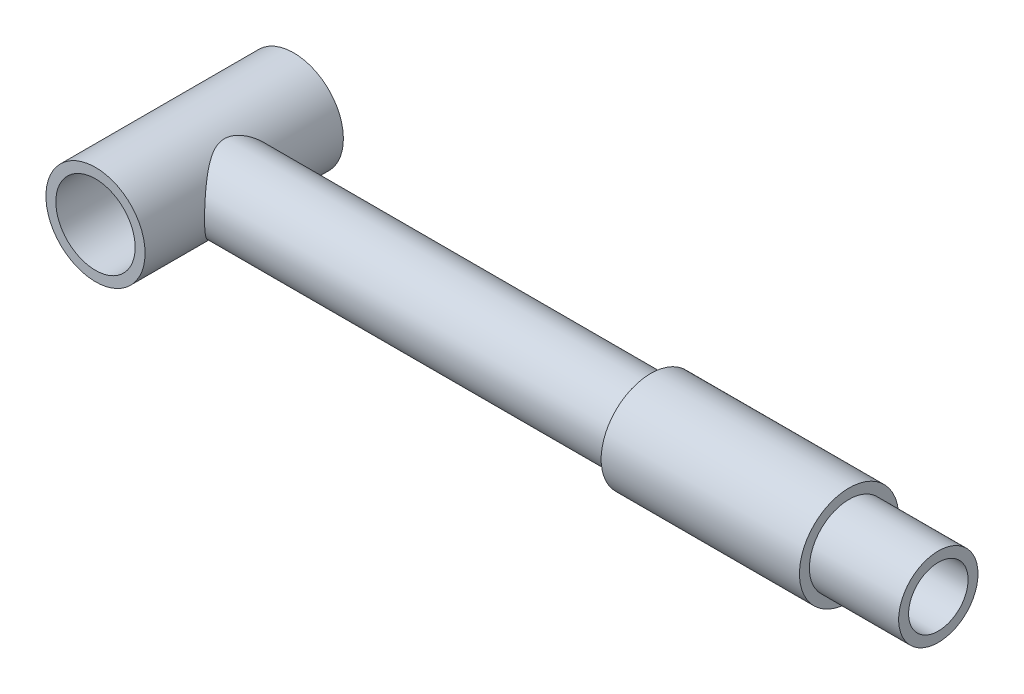
from build123d import *

# Parameters (mm, degrees)
IZIM1_R                                 = 2.5
IZIM1_R_2                               = 2
Y_KSEKLIK_EKSTR_ZYON1_DEPTH             = 5
IZIM2_R                                 = 2
IZIM2_R_2                               = 1.5
Y_KSEKLIK_EKSTR_ZYON2_DEPTH             = 35
Y_KSEKLIK_EKSTR_ZYON2_DIRECTION_2_REACH = 7
IZIM3_R                                 = 2.5
IZIM3_R_2                               = 2
Y_KSEKLIK_EKSTR_ZYON3_DEPTH             = 10


with BuildPart() as part:
    # Çizim1 → Yükseklik-Ekstrüzyon1 (new body, symmetric)
    with BuildSketch(Plane.XY):
        Circle(IZIM1_R)
        Circle(IZIM1_R_2, mode=Mode.SUBTRACT)
    extrude(amount=Y_KSEKLIK_EKSTR_ZYON1_DEPTH, both=True)

    # Çizim2 → Yükseklik-Ekstrüzyon2 (add)
    with BuildSketch(Plane(origin=(2.5, 0, 0), x_dir=(0, 0, -1), z_dir=(1, 0, 0))):
        Circle(IZIM2_R)
        Circle(IZIM2_R_2, mode=Mode.SUBTRACT)
    extrude(amount=Y_KSEKLIK_EKSTR_ZYON2_DEPTH)

    # Çizim2 → Yükseklik-Ekstrüzyon2 direction 2 (add, up to next)
    with BuildSketch(Plane(origin=(2.5, 0, 0), x_dir=(0, 0, -1), z_dir=(1, 0, 0)), mode=Mode.PRIVATE) as y_kseklik_ekstr_zyon2_direction_2_sk1:
        Circle(IZIM2_R)
        Circle(IZIM2_R_2, mode=Mode.SUBTRACT)
    y_kseklik_ekstr_zyon2_direction_2_tool1 = extrude(y_kseklik_ekstr_zyon2_direction_2_sk1.sketch, amount=-Y_KSEKLIK_EKSTR_ZYON2_DIRECTION_2_REACH, mode=Mode.PRIVATE) - part.part
    add(y_kseklik_ekstr_zyon2_direction_2_tool1.solids().sort_by_distance((2.5, 0, 1.943431))[0])
    add(y_kseklik_ekstr_zyon2_direction_2_tool1.solids().sort_by_distance((2.5, 0, 1.943431))[1])

    # Çizim3 → Yükseklik-Ekstrüzyon3 (add)
    with BuildSketch(Plane(origin=(32.997737042, 0, 0), x_dir=(0, 0, -1), z_dir=(1, 0, 0))):
        Circle(IZIM3_R)
        Circle(IZIM3_R_2, mode=Mode.SUBTRACT)
    extrude(amount=-Y_KSEKLIK_EKSTR_ZYON3_DEPTH)


solid = part.part
